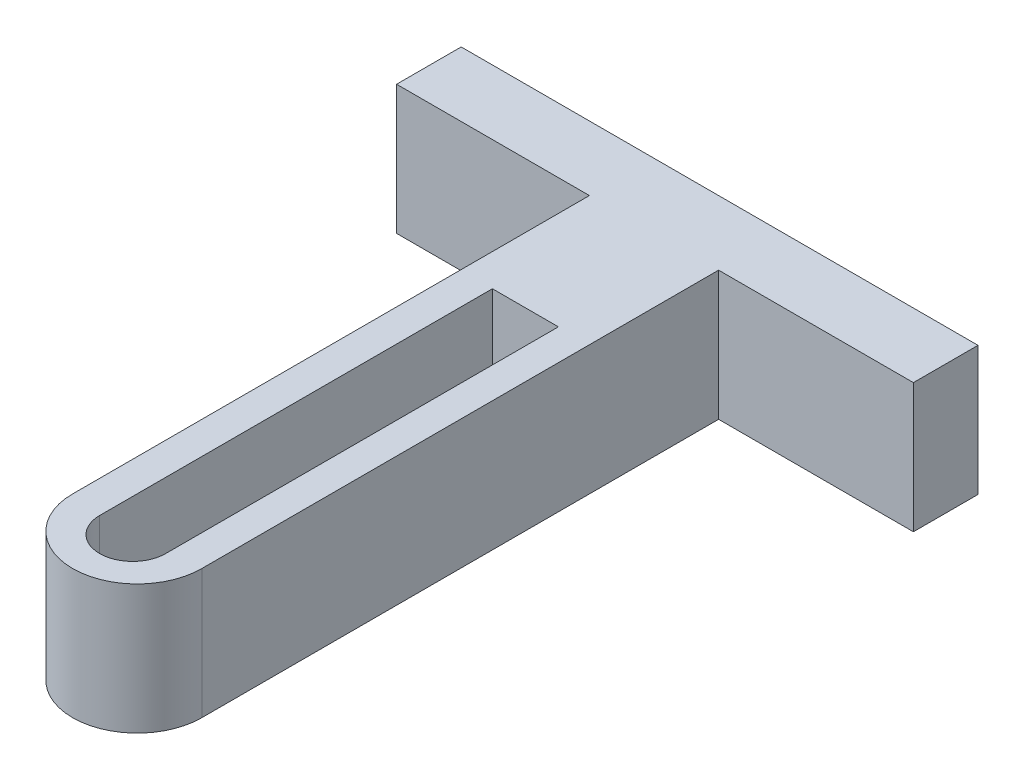
from build123d import *

# Parameters (mm, degrees)
SKETCH1_W           = 50.8
SKETCH1_H           = 12.7
BOSS_EXTRUDE1_DEPTH = 6.35
BOSS_EXTRUDE2_DEPTH = 12.7


with BuildPart() as part:
    # Sketch1 → Boss-Extrude1 (new body)
    with BuildSketch(Plane.XY):
        with Locations((25.4, 6.35)):
            Rectangle(SKETCH1_W, SKETCH1_H)
    extrude(amount=BOSS_EXTRUDE1_DEPTH)

    # Sketch4 → Boss-Extrude2 (add)
    with BuildSketch(Plane.XZ):
        with BuildLine():
            Line((18.953484491, 6.35), (31.653484491, 6.35))
            Line((31.653484491, 6.35), (31.653484491, 57.15))
            ThreePointArc((31.653484491, 57.15), (25.303484491, 63.5), (18.953484491, 57.15))
            Line((18.953484491, 57.15), (18.953484491, 6.35))
        make_face()
        with BuildLine():
            Line((22.117326524, 57.65327603), (22.117326524, 19.05))
            Line((22.117326524, 19.05), (28.605484491, 19.05))
            Line((28.605484491, 19.05), (28.605484491, 57.65327603))
            ThreePointArc((28.605484491, 57.65327603), (25.361405508, 60.897355013), (22.117326524, 57.65327603))
        make_face(mode=Mode.SUBTRACT)
    extrude(amount=-BOSS_EXTRUDE2_DEPTH)


solid = part.part
